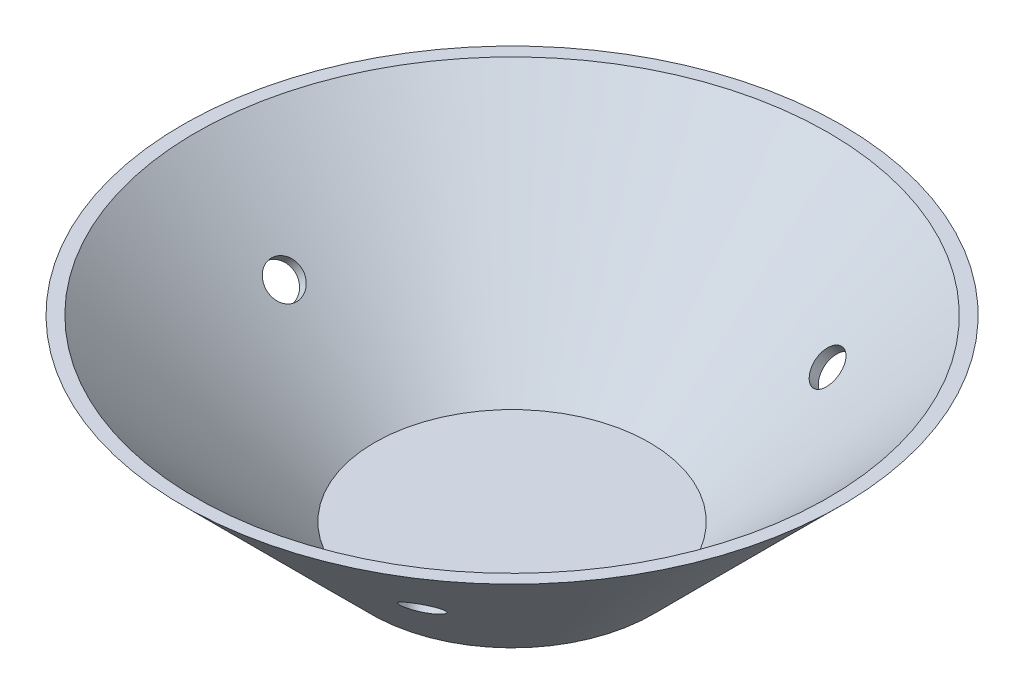
from build123d import *

# Parameters (mm, degrees)
CROQUIS5_R            = 1.9
CORTAR_EXTRUIR1_DEPTH = 50.497474683
MATRIZC1_COUNT        = 3


with BuildPart() as part:
    # Croquis4 → Revolución1 (revolve)
    with BuildSketch(Plane(origin=(0, 0, 0), x_dir=(0, 0, -1), z_dir=(1, 0, 0))):
        Polygon((-15, 0), (0, 0), (0, 1), (-14.585786438, 1), (-33.585786438, 20), (-35, 20), align=None)
    revolve(axis=Axis((0, 0, 0), (0, 1, 0)))

    # Croquis5 → Cortar-Extruir1 (cut, through all)
    with BuildSketch(Plane(origin=(-7.5, -7.5, -10.606601718), x_dir=(0.5, -0.5, -0.707106781), z_dir=(0.707106781, 0.707106781, 0))):
        with Locations((-25, 10.353571071)):
            Circle(CROQUIS5_R)
    cortar_extruir1 = extrude(amount=CORTAR_EXTRUIR1_DEPTH, mode=Mode.SUBTRACT)

    # MatrizC1: Cortar-Extruir1 ×3 about axis
    matrizc1_axis = Axis((0, 1, 0), (0, 1, 0))
    for i in range(1, MATRIZC1_COUNT):
        add(cortar_extruir1.rotate(matrizc1_axis, i * 360 / MATRIZC1_COUNT), mode=Mode.SUBTRACT)


solid = part.part
